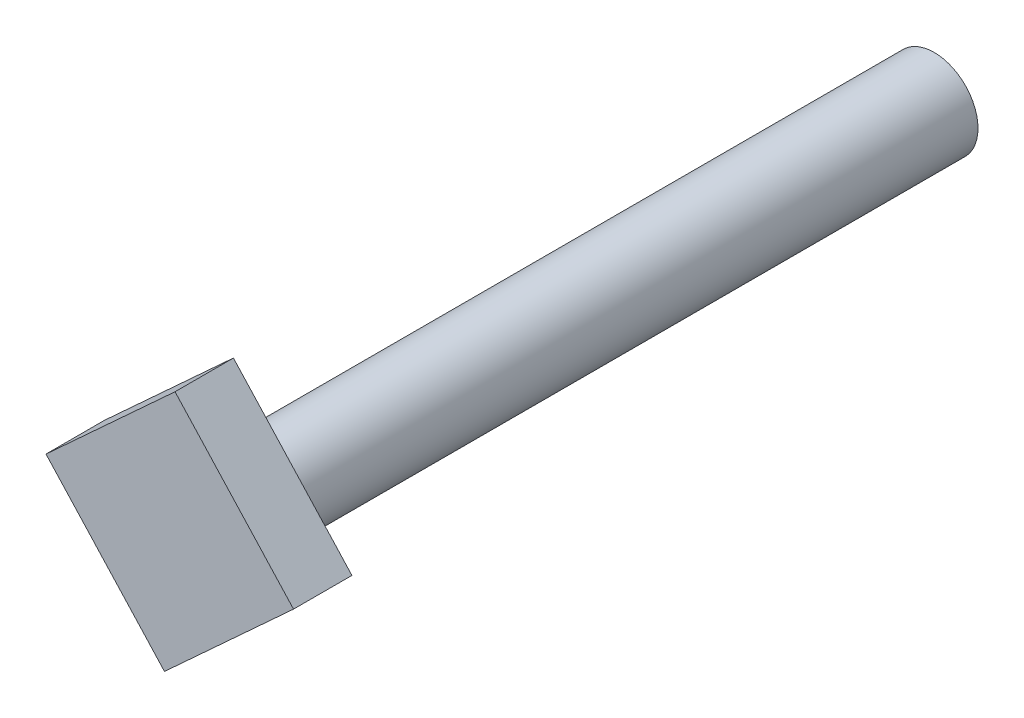
from build123d import *

# Parameters (mm, degrees)
BOSS_EXTRUDE1_DEPTH = 8
SKETCH4_R           = 6
BOSS_EXTRUDE2_DEPTH = 104


with BuildPart() as part:
    # Sketch2 → Boss-Extrude1 (new body)
    with BuildSketch(Plane.XY):
        Polygon((-17.678131714, 1.510354203), (0, 17.742533943), (16.23217974, 0.064402229), (-1.445951974, -16.167777511), align=None)
    extrude(amount=-BOSS_EXTRUDE1_DEPTH)

    # Sketch4 → Boss-Extrude2 (add)
    with BuildSketch(Plane.XY):
        Circle(SKETCH4_R)
    extrude(amount=-BOSS_EXTRUDE2_DEPTH)


solid = part.part
